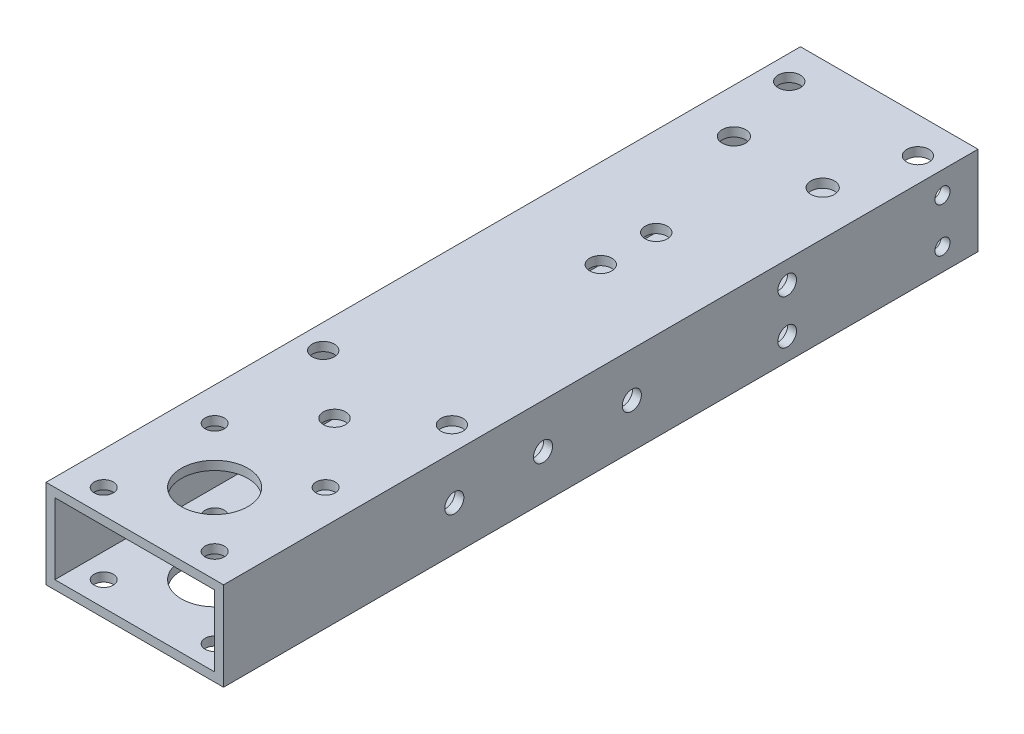
from build123d import *

# Parameters (mm, degrees)
SKETCH_1_W          = 40
SKETCH_1_H          = 20
SKETCH_1_W_2        = 36
SKETCH_1_H_2        = 16
EXTRUDE_1_DEPTH     = 190
SKETCH_3_R          = 2.15
SKETCH_3_R_2        = 7.5
CUT_EXTRUDE_2_DEPTH = 21
SKETCH_4_W          = 20
SKETCH_4_H          = 20
CUT_EXTRUDE_3_DEPTH = 41
SKETCH_5_R          = 2.5
CUT_EXTRUDE_4_DEPTH = 21
SKETCH_6_R          = 2.5
CUT_EXTRUDE_5_DEPTH = 21
SKETCH_7_R          = 2.65
CUT_EXTRUDE_6_DEPTH = 21
SKETCH_8_R          = 1.7
CUT_EXTRUDE_7_DEPTH = 41
SKETCH_9_R          = 2.1
SKETCH_9_R_2        = 2.15
CUT_EXTRUDE_8_DEPTH = 41


with BuildPart() as part:
    # 草图1 → 拉伸-薄壁1 (new body)
    with BuildSketch(Plane.XY):
        Rectangle(SKETCH_1_W, SKETCH_1_H)
        Rectangle(SKETCH_1_W_2, SKETCH_1_H_2, mode=Mode.SUBTRACT)
    extrude(amount=EXTRUDE_1_DEPTH)

    # 草图3 → 切除-拉伸2 (cut, through all)
    with BuildSketch(Plane(origin=(0, 10, 0), x_dir=(1, 0, 0), z_dir=(0, 1, 0))):
        with Locations((-12.5, -184.5)):
            Circle(SKETCH_3_R)
        with Locations((-12.5, -159.5)):
            Circle(SKETCH_3_R)
        with Locations((12.5, -159.5)):
            Circle(SKETCH_3_R)
        with Locations((12.5, -184.5)):
            Circle(SKETCH_3_R)
        with Locations((0, -172)):
            Circle(SKETCH_3_R_2)
    extrude(amount=-CUT_EXTRUDE_2_DEPTH, mode=Mode.SUBTRACT)

    # 草图4 → 切除-拉伸3 (cut, through all)
    with BuildSketch(Plane(origin=(20, 0, 0), x_dir=(0, 0, -1), z_dir=(1, 0, 0))):
        with Locations((-10, 0)):
            Rectangle(SKETCH_4_W, SKETCH_4_H)
    extrude(amount=-CUT_EXTRUDE_3_DEPTH, mode=Mode.SUBTRACT)

    # 草图5 → 切除-拉伸4 (cut, through all)
    with BuildSketch(Plane(origin=(0, 10, 0), x_dir=(1, 0, 0), z_dir=(0, 1, 0))):
        with Locations((0, -145)):
            Circle(SKETCH_5_R)
        with Locations((0, -85)):
            Circle(SKETCH_5_R)
        with Locations((0, -72.5)):
            Circle(SKETCH_5_R)
    extrude(amount=-CUT_EXTRUDE_4_DEPTH, mode=Mode.SUBTRACT)

    # 草图6 → 切除-拉伸5 (cut, through all)
    with BuildSketch(Plane(origin=(0, 10, 0), x_dir=(1, 0, 0), z_dir=(0, 1, 0))):
        with Locations((-14.5, -133.038475773)):
            Circle(SKETCH_6_R)
        with Locations((14.5, -133.038475773)):
            Circle(SKETCH_6_R)
        with Locations((14.5, -28.038475773)):
            Circle(SKETCH_6_R)
        with Locations((-14.5, -28.038475773)):
            Circle(SKETCH_6_R)
    extrude(amount=-CUT_EXTRUDE_5_DEPTH, mode=Mode.SUBTRACT)

    # 草图7 → 切除-拉伸6 (cut, through all)
    with BuildSketch(Plane.XZ.offset(10)):
        with Locations((-10, 45)):
            Circle(SKETCH_7_R)
        with Locations((10, 45)):
            Circle(SKETCH_7_R)
    extrude(amount=-CUT_EXTRUDE_6_DEPTH, mode=Mode.SUBTRACT)

    # 草图8 → 切除-拉伸7 (cut, through all)
    with BuildSketch(Plane(origin=(20, 0, 0), x_dir=(0, 0, -1), z_dir=(1, 0, 0))):
        with Locations((-28, 5)):
            Circle(SKETCH_8_R)
        with Locations((-28, -5)):
            Circle(SKETCH_8_R)
    extrude(amount=-CUT_EXTRUDE_7_DEPTH, mode=Mode.SUBTRACT)

    # 草图9 → 切除-拉伸8 (cut, through all)
    with BuildSketch(Plane.ZY.offset(20)):
        with Locations((63, -5)):
            Circle(SKETCH_9_R)
        with Locations((63, 5)):
            Circle(SKETCH_9_R)
        with Locations((98, 0)):
            Circle(SKETCH_9_R_2)
        with Locations((118, 0)):
            Circle(SKETCH_9_R_2)
        with Locations((138, 0)):
            Circle(SKETCH_9_R_2)
    extrude(amount=-CUT_EXTRUDE_8_DEPTH, mode=Mode.SUBTRACT)


solid = part.part
